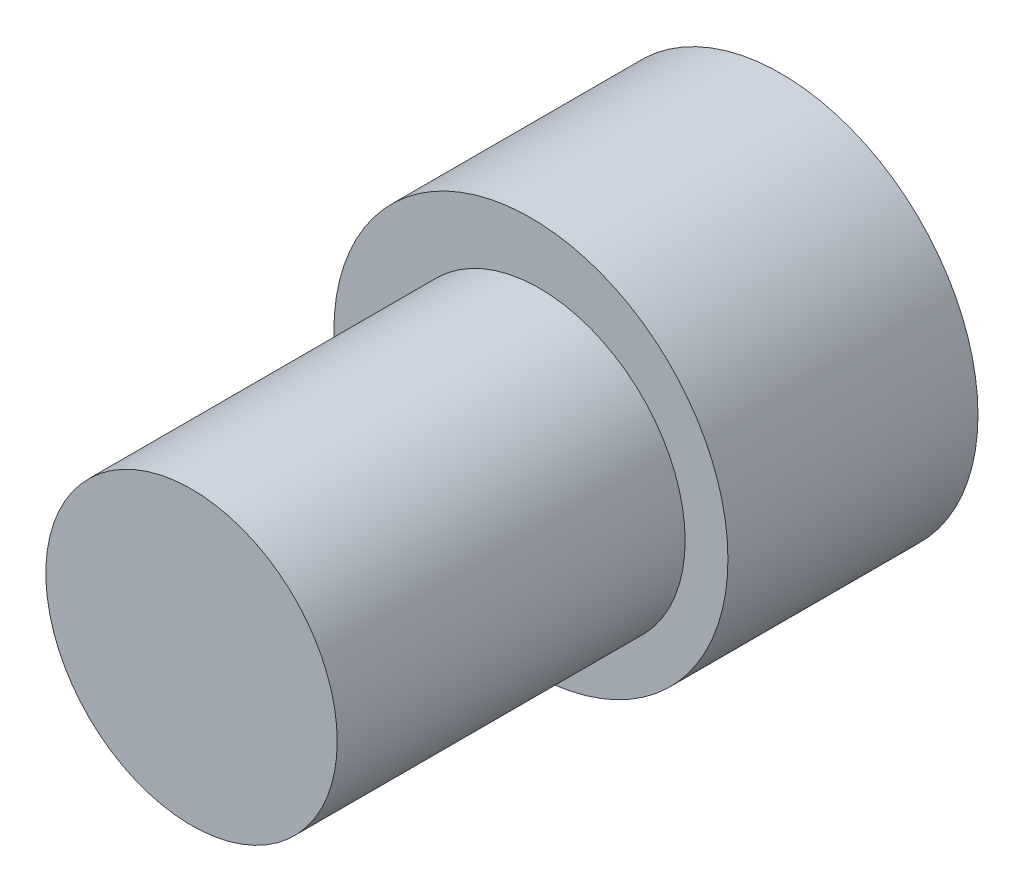
from build123d import *

# Parameters (mm, degrees)
SKETCH3_R           = 3.35
BOSS_EXTRUDE2_DEPTH = 8
SKETCH6_R           = 4.531192519
BOSS_EXTRUDE5_DEPTH = 5.75


with BuildPart() as part:
    # Sketch3 → Boss-Extrude2 (new body)
    with BuildSketch(Plane.XY.offset(-19.241356107)):
        with Locations((-23.430554745, 35.572087407)):
            Circle(SKETCH3_R)
    extrude(amount=-BOSS_EXTRUDE2_DEPTH)

    # Sketch6 → Boss-Extrude5 (add)
    with BuildSketch(Plane(origin=(0, 0, -27.241356107), x_dir=(-1, 0, 0), z_dir=(0, 0, -1))):
        with Locations((23.627770675, 35.693334986)):
            Circle(SKETCH6_R)
    extrude(amount=BOSS_EXTRUDE5_DEPTH)


solid = part.part
